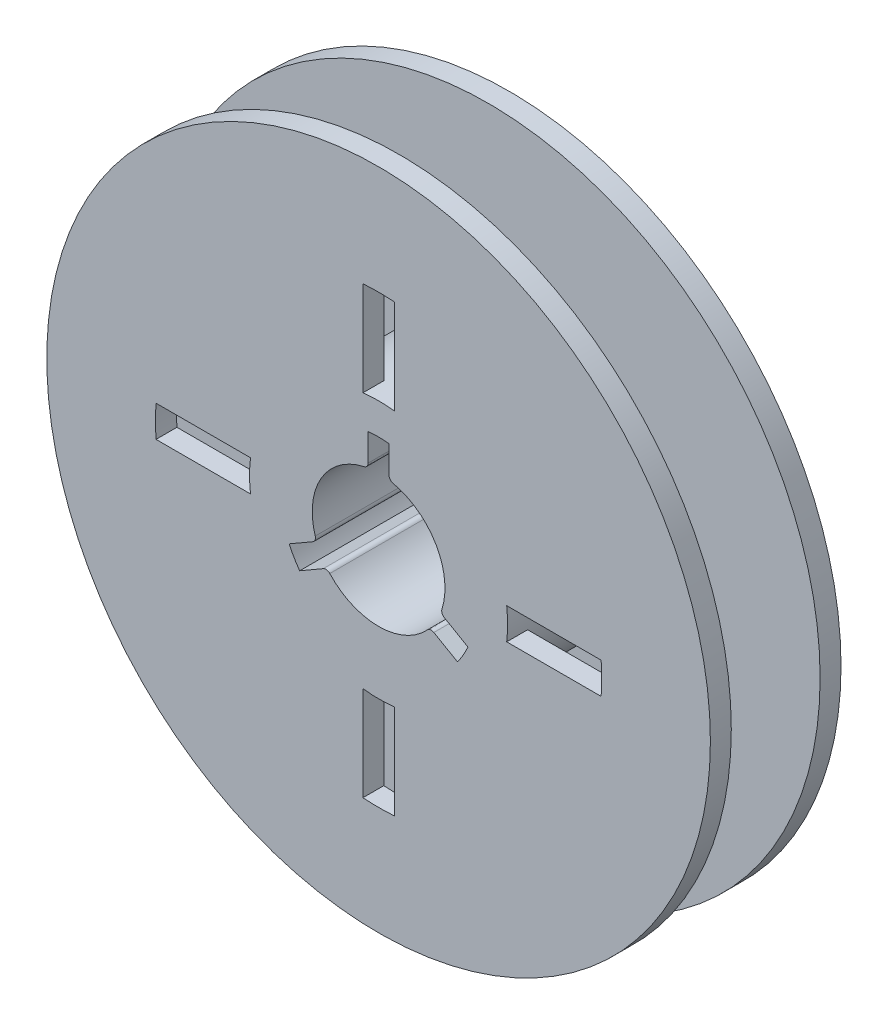
from build123d import *

# Parameters (mm, degrees)
SKETCH1_R           = 31.75
BOSS_EXTRUDE1_DEPTH = 2
SKETCH3_R           = 12.35
BOSS_EXTRUDE3_DEPTH = 4.25
CUT_EXTRUDE1_DEPTH  = 47.608743815


with BuildPart() as part:
    # Sketch1 → Boss-Extrude1 (new body)
    with BuildSketch(Plane.XY):
        Circle(SKETCH1_R)
        with BuildLine():
            Line((1.5, 12.258568432), (1.5, 21.297241605))
            ThreePointArc((1.5, 21.297241605), (0, 21.35), (-1.5, 21.297241605))
            Line((-1.5, 21.297241605), (-1.5, 12.258568432))
            ThreePointArc((-1.5, 12.258568432), (0, 12.35), (1.5, 12.258568432))
        make_face(mode=Mode.SUBTRACT)
        with BuildLine():
            Line((-12.258568432, 1.5), (-21.297241605, 1.5))
            ThreePointArc((-21.297241605, 1.5), (-21.35, 0), (-21.297241605, -1.5))
            Line((-21.297241605, -1.5), (-12.258568432, -1.5))
            ThreePointArc((-12.258568432, -1.5), (-12.35, 0), (-12.258568432, 1.5))
        make_face(mode=Mode.SUBTRACT)
        with BuildLine():
            Line((-1.5, -12.258568432), (-1.5, -21.297241605))
            ThreePointArc((-1.5, -21.297241605), (0, -21.35), (1.5, -21.297241605))
            Line((1.5, -21.297241605), (1.5, -12.258568432))
            ThreePointArc((1.5, -12.258568432), (0, -12.35), (-1.5, -12.258568432))
        make_face(mode=Mode.SUBTRACT)
        with BuildLine():
            Line((12.258568432, -1.5), (21.297241605, -1.5))
            ThreePointArc((21.297241605, -1.5), (21.35, 0), (21.297241605, 1.5))
            Line((21.297241605, 1.5), (12.258568432, 1.5))
            ThreePointArc((12.258568432, 1.5), (12.35, 0), (12.258568432, -1.5))
        make_face(mode=Mode.SUBTRACT)
    extrude(amount=BOSS_EXTRUDE1_DEPTH)

    # Sketch3 → Boss-Extrude3 (add)
    with BuildSketch(Plane.XY.offset(2)):
        with Locations(Location((0, 0, 0), (0, 0, 173.023774077))):
            Circle(SKETCH3_R)
    extrude(amount=BOSS_EXTRUDE3_DEPTH)

    # Mirror1: part across plane


with BuildPart() as part_1:
    add(part.part)
    add(part.part.mirror(Plane.XY.offset(6.25)))

    # Sketch4 → Cut-Extrude1 (cut, through all)
    with BuildSketch(Plane(origin=(0, 0, 0), x_dir=(-1, 0, 0), z_dir=(0, 0, -1))):
        with BuildLine():
            Line((1, 6.683748948), (1, 9.296370259))
            ThreePointArc((1, 9.296370259), (0, 9.35), (-1, 9.296370259))
            Line((-1, 9.296370259), (-1, 6.683748948))
            ThreePointArc((-1, 6.683748948), (-1.109651101, 6.371294572), (-1.390510949, 6.195884061))
            ThreePointArc((-1.390510949, 6.195884061), (-5.499261314, 3.175), (-6.06104847, -1.893724225))
            ThreePointArc((-6.06104847, -1.893724225), (-6.072528505, -2.224661243), (-6.288296381, -2.47584907))
            Line((-6.288296381, -2.47584907), (-8.550892808, -3.782159726))
            ThreePointArc((-8.550892808, -3.782159726), (-8.097337525, -4.675), (-7.550892808, -5.514210533))
            Line((-7.550892808, -5.514210533), (-5.288296381, -4.207899878))
            ThreePointArc((-5.288296381, -4.207899878), (-4.962877404, -4.146633329), (-4.670537522, -4.302159837))
            ThreePointArc((-4.670537522, -4.302159837), (0, -6.35), (4.670537522, -4.302159837))
            ThreePointArc((4.670537522, -4.302159837), (4.962877404, -4.146633329), (5.288296381, -4.207899878))
            Line((5.288296381, -4.207899878), (7.550892808, -5.514210533))
            ThreePointArc((7.550892808, -5.514210533), (8.097337525, -4.675), (8.550892808, -3.782159726))
            Line((8.550892808, -3.782159726), (6.288296381, -2.47584907))
            ThreePointArc((6.288296381, -2.47584907), (6.072528505, -2.224661243), (6.06104847, -1.893724225))
            ThreePointArc((6.06104847, -1.893724225), (5.499261314, 3.175), (1.390510949, 6.195884061))
            ThreePointArc((1.390510949, 6.195884061), (1.109651101, 6.371294572), (1, 6.683748948))
        make_face()
    extrude(amount=-CUT_EXTRUDE1_DEPTH, mode=Mode.SUBTRACT)


solid = part_1.part
